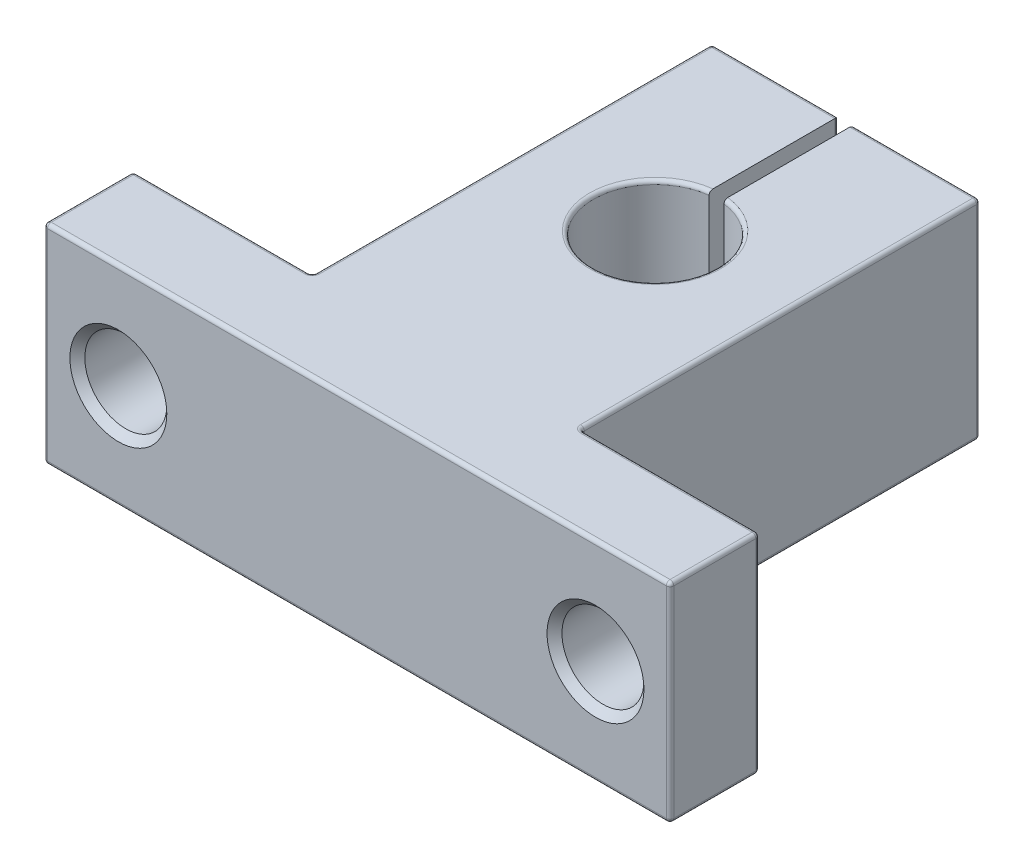
from build123d import *

# Parameters (mm, degrees)
BOSS_EXTRUDE1_DEPTH      = 7
BOSS_EXTRUDE1_DEPTH_BACK = 7
CUT_EXTRUDE1_REACH       = 41.571
SKETCH2_R                = 2.75
FILLET1_R                = 0.25
CHAMFER1_SIZE            = 0.5


with BuildPart() as part:
    # Sketch1 → Boss-Extrude1 (new, two sides: drawn at the far end of the back side and taken through both)
    with BuildSketch(Plane(origin=(0, 0, 0), x_dir=(1, 0, 0), z_dir=(0, 1, 0)).offset(-BOSS_EXTRUDE1_DEPTH_BACK)):
        with BuildLine():
            Line((-21, 6), (-21, 0))
            Line((-21, 0), (21, 0))
            Line((21, 0), (21, 6))
            Line((21, 6), (9, 6))
            Line((9, 6), (9, 32.8))
            Line((9, 32.8), (0.5, 32.8))
            Line((0.5, 32.8), (0.5, 24.119769411))
            ThreePointArc((0.5, 24.119769411), (0, 15.85), (-0.5, 24.119769411))
            Line((-0.5, 24.119769411), (-0.5, 32.8))
            Line((-0.5, 32.8), (-9, 32.8))
            Line((-9, 32.8), (-9, 6))
            Line((-9, 6), (-21, 6))
        make_face()
    extrude(amount=BOSS_EXTRUDE1_DEPTH + BOSS_EXTRUDE1_DEPTH_BACK)

    # Sketch2 → Cut-Extrude1 (cut, up to next)
    with BuildSketch(Plane.XY, mode=Mode.PRIVATE) as cut_extrude1_sk1:
        with Locations((-16, 0)):
            Circle(SKETCH2_R)
    cut_extrude1_tool1 = extrude(cut_extrude1_sk1.sketch, amount=-CUT_EXTRUDE1_REACH, mode=Mode.PRIVATE) & part.part
    # Sketch2 → Cut-Extrude1 (cut, up to next)
    with BuildSketch(Plane.XY, mode=Mode.PRIVATE) as cut_extrude1_sk2:
        with Locations((16, 0)):
            Circle(SKETCH2_R)
    cut_extrude1_tool2 = extrude(cut_extrude1_sk2.sketch, amount=-CUT_EXTRUDE1_REACH, mode=Mode.PRIVATE) & part.part
    add(cut_extrude1_tool1.solids().sort_by_distance((-16, 0, 0))[0], mode=Mode.SUBTRACT)
    add(cut_extrude1_tool2.solids().sort_by_distance((16, 0, 0))[0], mode=Mode.SUBTRACT)

    # Fillet1
    fillet1_edges = [part.edges().sort_by_distance(p)[0] for p in [
        (15, -7, -6),
        (15, 7, -6),
        (-9, -7, -19.4),
        (-9, 7, -19.4),
        (9, -7, -19.4),
        (9, 0, -6),
        (9, 7, -19.4),
        (4.75, -7, -32.8),
        (9, 0, -32.8),
        (4.75, 7, -32.8),
        (0.5, 0, -32.8),
        (-4.75, -7, -32.8),
        (-0.5, 0, -32.8),
        (-4.75, 7, -32.8),
        (-9, 0, -32.8),
        (21, 0, 0),
        (-21, 0, 0),
        (0, 7, 0),
        (0, -7, 0),
        (21, -7, -3),
        (-21, -7, -3),
        (-21, 7, -3),
        (21, 7, -3),
        (-15, -7, -6),
        (-21, 0, -6),
        (-15, 7, -6),
        (-9, 0, -6),
        (21, 0, -6),
        (0, -7, -15.85),
        (0, 7, -15.85),
    ]]
    fillet(fillet1_edges, radius=FILLET1_R)

    # Chamfer1
    chamfer1_edges = [part.edges().sort_by_distance(p)[0] for p in [
        (13.25, 0, 0),
        (-18.75, 0, 0),
        (-18.75, 0, -6),
        (13.25, 0, -6),
    ]]
    chamfer(chamfer1_edges, length=CHAMFER1_SIZE)


solid = part.part
